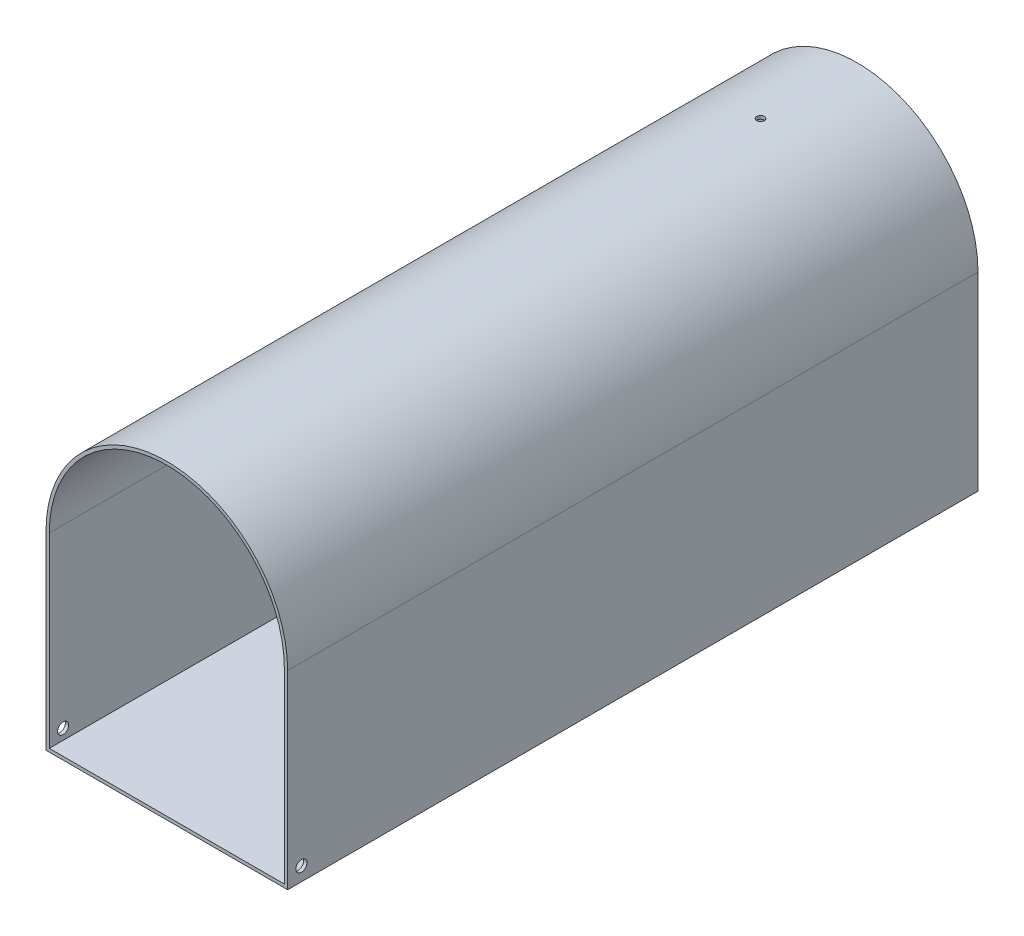
from build123d import *

# Parameters (mm, degrees)
BOSS_EXTRUDE1_DEPTH = 500
CUT_EXTRUDE1_DEPTH  = 497
SKETCH3_R           = 4
CUT_EXTRUDE2_DEPTH  = 497
SKETCH4_R           = 2.75
CUT_EXTRUDE3_DEPTH  = 5


with BuildPart() as part:
    # Sketch1 → Boss-Extrude1 (new body)
    with BuildSketch(Plane.XY):
        with BuildLine():
            Line((0, 0), (175, 0))
            Line((175, 0), (175, 137.5))
            ThreePointArc((175, 137.5), (87.5, 225), (0, 137.5))
            Line((0, 137.5), (0, 0))
        make_face()
    extrude(amount=BOSS_EXTRUDE1_DEPTH)

    # Sketch2 → Cut-Extrude1 (cut)
    with BuildSketch(Plane.XY.offset(500)):
        with BuildLine():
            Line((172.61875, 2.38125), (172.61875, 137.5))
            ThreePointArc((172.61875, 137.5), (87.5, 222.61875), (2.38125, 137.5))
            Line((2.38125, 137.5), (2.38125, 2.38125))
            Line((2.38125, 2.38125), (172.61875, 2.38125))
        make_face()
    extrude(amount=-CUT_EXTRUDE1_DEPTH, mode=Mode.SUBTRACT)

    # Sketch3 → Cut-Extrude2 (cut)
    with BuildSketch(Plane(origin=(175, 0, 0), x_dir=(0, 0, -1), z_dir=(1, 0, 0))):
        with Locations((-490, 10)):
            Circle(SKETCH3_R)
    extrude(amount=-CUT_EXTRUDE2_DEPTH, mode=Mode.SUBTRACT)

    # Sketch4 → Cut-Extrude3 (cut)
    with BuildSketch(Plane(origin=(0, 225, 0), x_dir=(1, 0, 0), z_dir=(0, 1, 0))):
        with Locations((87.5, -70)):
            Circle(SKETCH4_R)
    extrude(amount=-CUT_EXTRUDE3_DEPTH, mode=Mode.SUBTRACT)


solid = part.part
